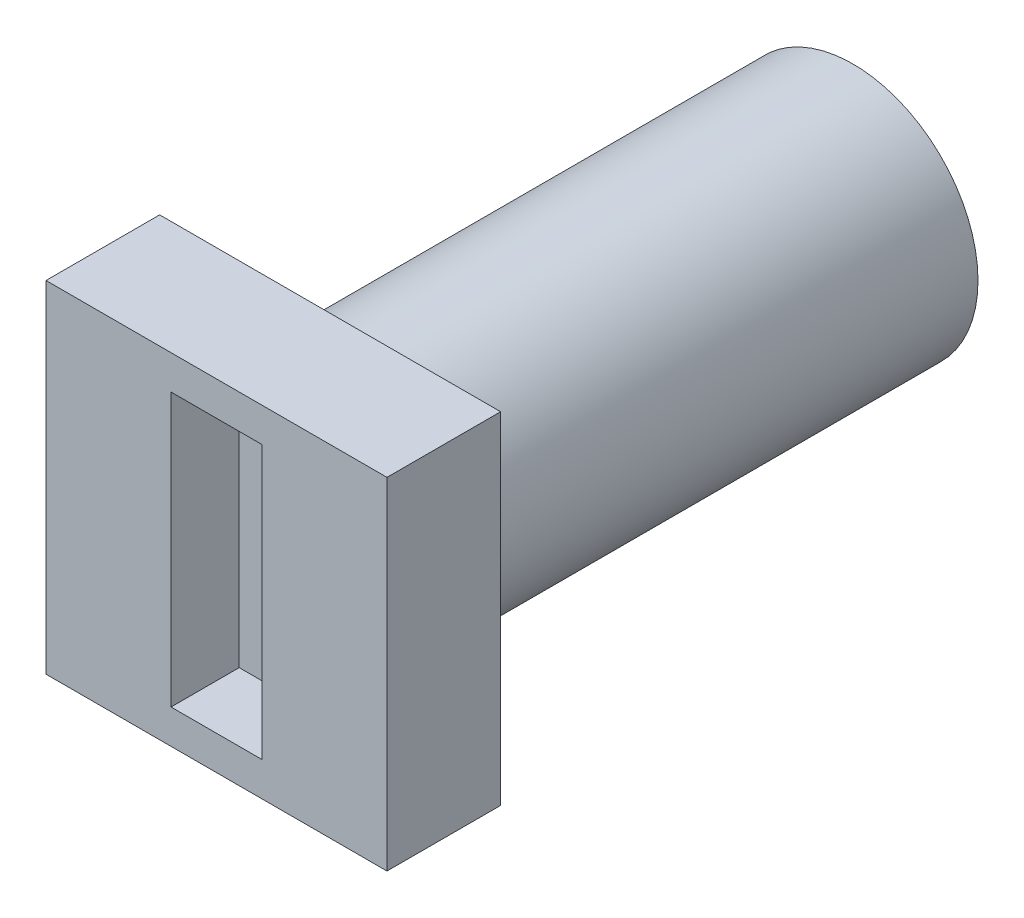
from build123d import *

# Parameters (mm, degrees)
BOSS_EXTRU_1_DEPTH                = 23
DIAM_TRE_DU_PER_AGE_2_0_2_1_D     = 2
DIAM_TRE_DU_PER_AGE_2_0_2_1_DEPTH = 3
ESQUISSE4_W                       = 15
ESQUISSE4_H                       = 15
BOSS_EXTRU_3_DEPTH                = 2
ESQUISSE6_W                       = 15
ESQUISSE6_H                       = 15
ESQUISSE6_W_2                     = 4
ESQUISSE6_H_2                     = 12
BOSS_EXTRU_4_DEPTH                = 3


with BuildPart() as part:
    # Esquisse1 → Boss.-Extru.1 (new body)
    with BuildSketch(Plane.XY):
        with BuildLine():
            Line((-5, 2.291287847), (-5, -2.291287847))
            ThreePointArc((-5, -2.291287847), (5.5, 0), (-5, 2.291287847))
        make_face()
        with BuildLine():
            Line((-2, 1.5), (-2, -1.5))
            ThreePointArc((-2, -1.5), (2.5, 0), (-2, 1.5))
        make_face(mode=Mode.SUBTRACT)
    extrude(amount=BOSS_EXTRU_1_DEPTH)

    # Diamètre du perçage Ø2.0 (2)1
    with Locations(Plane(origin=(-5, -0.001287847, 3.5), x_dir=(0, 0, -1), z_dir=(-1, 0, 0))):
        with Locations((0, 0), (-8, 0)):
            Hole(DIAM_TRE_DU_PER_AGE_2_0_2_1_D / 2, depth=DIAM_TRE_DU_PER_AGE_2_0_2_1_DEPTH)

    # Esquisse4 → Boss.-Extru.3 (add)
    with BuildSketch(Plane.XY.offset(23)):
        Rectangle(ESQUISSE4_W, ESQUISSE4_H)
    extrude(amount=BOSS_EXTRU_3_DEPTH)

    # Esquisse6 → Boss.-Extru.4 (add)
    with BuildSketch(Plane.XY.offset(25)):
        Rectangle(ESQUISSE6_W, ESQUISSE6_H)
        Rectangle(ESQUISSE6_W_2, ESQUISSE6_H_2, mode=Mode.SUBTRACT)
    extrude(amount=BOSS_EXTRU_4_DEPTH)


solid = part.part
